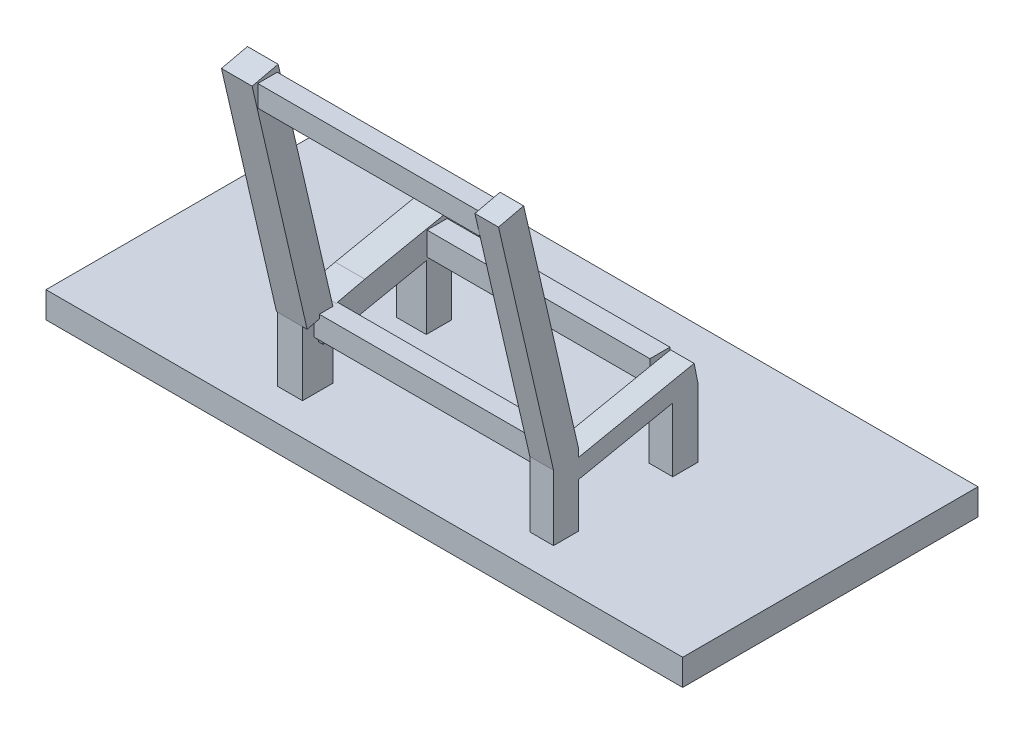
from build123d import *

# Parameters (mm, degrees)
SKETCH1_W           = 72.965111838
SKETCH1_H           = 33.844166588
BOSS_EXTRUDE1_DEPTH = 3
SKETCH3_W           = 2.882114132
SKETCH3_H           = 3.51617924
SKETCH3_W_2         = 2.709187283
SKETCH3_H_2         = 2.882114131
SKETCH3_W_3         = 3.400894675
BOSS_EXTRUDE3_DEPTH = 20
CUT_EXTRUDE1_DEPTH  = 55.486301037
CUT_EXTRUDE3_DEPTH  = 55.486301037
SKETCH7_W           = 3.400894675
SKETCH7_H           = 3.059488665
SKETCH7_W_2         = 2.709187283
SKETCH7_H_2         = 2.154943678
BOSS_EXTRUDE4_DEPTH = 15
CUT_EXTRUDE4_DEPTH  = 51.12442396
SKETCH10_W          = 3.51617924
SKETCH10_H          = 3.055040979
SKETCH10_W_2        = 2.709187283
SKETCH10_H_2        = 2.958051749
BOSS_EXTRUDE6_DEPTH = 28
SKETCH8_W           = 2.299055041
SKETCH8_H           = 2.680852622
SKETCH8_W_2         = 2.227434614
SKETCH8_H_2         = 2.567737125
SKETCH8_W_3         = 2.227434615
SKETCH8_H_3         = 2.443990758
BOSS_EXTRUDE5_DEPTH = 28
SCALE1_SCALE        = 20


with BuildPart() as part:
    # Sketch1 → Boss-Extrude1 (new body)
    with BuildSketch(Plane(origin=(0, 0, 0), x_dir=(1, 0, 0), z_dir=(0, 1, 0))):
        with Locations((0.585613341, 9.227964694)):
            Rectangle(SKETCH1_W, SKETCH1_H)
    extrude(amount=BOSS_EXTRUDE1_DEPTH)

    # Sketch3 → Boss-Extrude3 (add)
    with BuildSketch(Plane(origin=(0, 3, 0), x_dir=(1, 0, 0), z_dir=(0, 1, 0))):
        with Locations((-11.615197635, -2.259085776)):
            Rectangle(SKETCH3_W, SKETCH3_H)
        with Locations((17.234764818, -2.57611833)):
            Rectangle(SKETCH3_W_2, SKETCH3_H_2)
        with Locations((-11.355807364, 11.085102651)):
            Rectangle(SKETCH3_W_3, SKETCH3_H_2)
        with Locations((17.234764818, 11.085102651)):
            Rectangle(SKETCH3_W_2, SKETCH3_H_2)
    extrude(amount=BOSS_EXTRUDE3_DEPTH)

    # Sketch5 → Cut-Extrude1 (cut, through all)
    with BuildSketch(Plane(origin=(18.589358459, 0, 0), x_dir=(0, 0, -1), z_dir=(1, 0, 0))):
        Polygon((-4.017175396, 23), (12.526159716, 20.968733862), (12.526159716, 23), align=None)
    extrude(amount=-CUT_EXTRUDE1_DEPTH, mode=Mode.SUBTRACT)

    # Sketch6 → Cut-Extrude3 (cut, through all)
    with BuildSketch(Plane(origin=(18.589358459, 0, 0), x_dir=(0, 0, -1), z_dir=(1, 0, 0))):
        Polygon((9.644045585, 10.32932434), (12.526159716, 10.917119585), (13.851707109, 22.456468353), (7.602515551, 22.796770863), align=None)
    extrude(amount=-CUT_EXTRUDE3_DEPTH, mode=Mode.SUBTRACT)

    # Sketch7 → Boss-Extrude4 (add)
    with BuildSketch(Plane(origin=(0, 2.888596131, -14.163543838), x_dir=(1, 0, 0), z_dir=(0, -0.199832296, 0.979830115))):
        with Locations((-11.355807364, 9.723535618)):
            Rectangle(SKETCH7_W, SKETCH7_H)
        with Locations((17.234764818, 9.271263124)):
            Rectangle(SKETCH7_W_2, SKETCH7_H_2)
    extrude(amount=BOSS_EXTRUDE4_DEPTH)

    # Sketch9 → Cut-Extrude4 (cut, through all)
    with BuildSketch(Plane.ZY.offset(13.056254701)):
        Polygon((-2.606877382, 12.016591514), (17.070701075, 7.469836516), (5.032523644, 29.000673684), (-3.876788288, 23.485385345), align=None)
    extrude(amount=-CUT_EXTRUDE4_DEPTH, mode=Mode.SUBTRACT)

    # Sketch10 → Boss-Extrude6 (add)
    with BuildSketch(Plane(origin=(0, 10.83572036, 2.503731128), x_dir=(1, 0, 0), z_dir=(0, 0.974328503, 0.225131004))):
        with Locations((-11.298165081, -0.134437641)):
            Rectangle(SKETCH10_W, SKETCH10_H)
        with Locations((17.234764818, -0.074294452)):
            Rectangle(SKETCH10_W_2, SKETCH10_H_2)
    extrude(amount=BOSS_EXTRUDE6_DEPTH)

    # Sketch8 → Boss-Extrude5 (add)
    with BuildSketch(Plane.ZY.offset(-15.880171176)):
        with Locations((-10.886667911, 11.97911657)):
            Rectangle(SKETCH8_W, SKETCH8_H)
        with Locations((1.616588826, 9.973553534)):
            Rectangle(SKETCH8_W_2, SKETCH8_H_2)
        with Locations((8.66740941, 36.463462875)):
            Rectangle(SKETCH8_W_3, SKETCH8_H_3)
    extrude(amount=BOSS_EXTRUDE5_DEPTH)


with BuildPart() as part_1:
    # Scale1: scaled about (0.71152725, 4.128027313, -7.668193293)
    add(part.part.scale(SCALE1_SCALE).moved(Location((-13.51901775, -78.432518947, 145.695672567))))


solid = part_1.part
